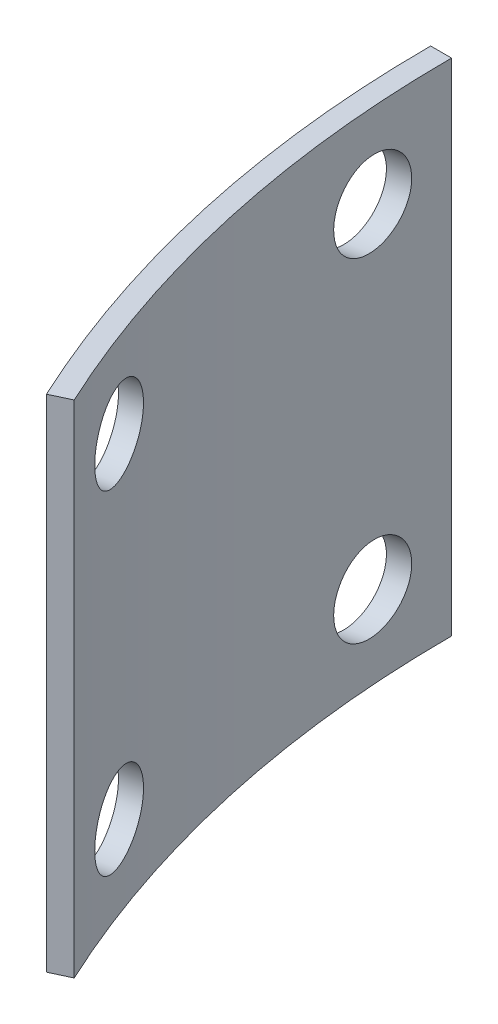
from build123d import *

# Parameters (mm, degrees)
BOSS_EXTRUDE1_DEPTH = 38.1
SKETCH3_R           = 3.175
CUT_EXTRUDE1_DEPTH  = 38.1


with BuildPart() as part:
    # Sketch2 → Boss-Extrude1 (new body)
    with BuildSketch(Plane(origin=(0, 0, 0), x_dir=(1, 0, 0), z_dir=(0, 1, 0))):
        with BuildLine():
            ThreePointArc((-79.131998656, -36.899856978), (-85.242845122, -18.897883792), (-87.3125, 0))
            Line((-87.3125, 0), (-88.9, 0))
            ThreePointArc((-88.9, 0), (-86.792715033, -19.241481679), (-80.570762268, -37.570763469))
            Line((-80.570762268, -37.570763469), (-79.131998656, -36.899856978))
        make_face()
    extrude(amount=BOSS_EXTRUDE1_DEPTH)

    # Sketch3 → Cut-Extrude1 (cut)
    with BuildSketch(Plane(origin=(-86.792715033, 0, 19.241481679), x_dir=(0, -1, 0), z_dir=(-0.976296007, 0, 0.216439614))):
        with Locations((-31.75, -12.7)):
            Circle(SKETCH3_R)
        with Locations((-31.75, 12.7)):
            Circle(SKETCH3_R)
        with Locations((-6.35, -12.7)):
            Circle(SKETCH3_R)
        with Locations((-6.35, 12.7)):
            Circle(SKETCH3_R)
    extrude(amount=-CUT_EXTRUDE1_DEPTH, mode=Mode.SUBTRACT)


solid = part.part
